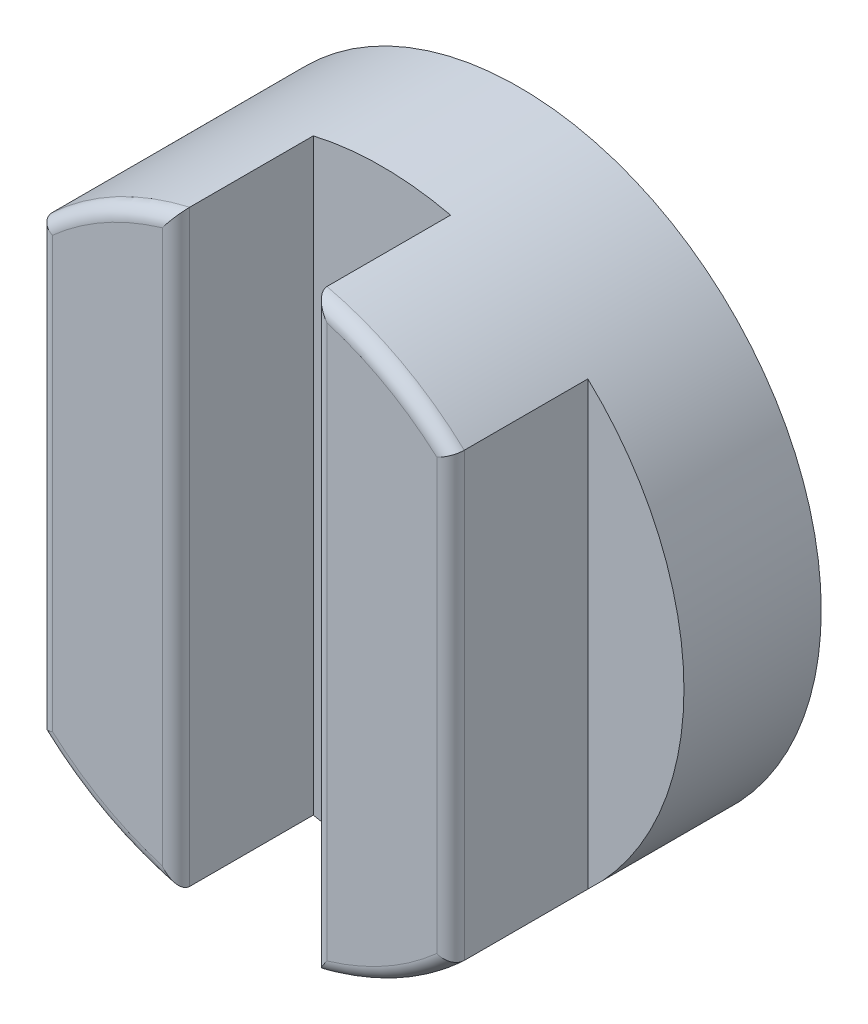
from build123d import *

# Parameters (mm, degrees)
ESQUISSE1_R        = 11
BOSS_EXTRU_1_DEPTH = 5
BOSS_EXTRU_3_DEPTH = 5
CONG_3_R           = 0.5


with BuildPart() as part:
    # Esquisse1 → Boss.-Extru.1 (new body)
    with BuildSketch(Plane.XY):
        Circle(ESQUISSE1_R)
    extrude(amount=BOSS_EXTRU_1_DEPTH)

    # Esquisse2 → Boss.-Extru.3 (add)
    with BuildSketch(Plane.XY.offset(5)):
        with BuildLine():
            ThreePointArc((-2.5, 10.712142643), (-5.174562286, 9.706899873), (-7.5, 8.04673847))
            Line((-7.5, 8.04673847), (-7.5, -8.04673847))
            ThreePointArc((-7.5, -8.04673847), (-5.174562286, -9.706899873), (-2.5, -10.712142643))
            Line((-2.5, -10.712142643), (-2.5, 10.712142643))
        make_face()
        with BuildLine():
            ThreePointArc((7.5, 8.04673847), (5.174562286, 9.706899873), (2.5, 10.712142643))
            Line((2.5, 10.712142643), (2.5, -10.712142643))
            ThreePointArc((2.5, -10.712142643), (5.174562286, -9.706899873), (7.5, -8.04673847))
            Line((7.5, -8.04673847), (7.5, 8.04673847))
        make_face()
    extrude(amount=BOSS_EXTRU_3_DEPTH)

    # Congé3
    cong_3_edges = [part.edges().sort_by_distance(p)[0] for p in [
        (5.174562286, 9.706899873, 10),
        (5.174562286, -9.706899873, 10),
        (7.5, 0, 10),
        (2.5, 0, 10),
        (-5.174562286, 9.706899873, 10),
        (-5.174562286, -9.706899873, 10),
        (-2.5, 0, 10),
        (-7.5, 0, 10),
    ]]
    fillet(cong_3_edges, radius=CONG_3_R)


solid = part.part
